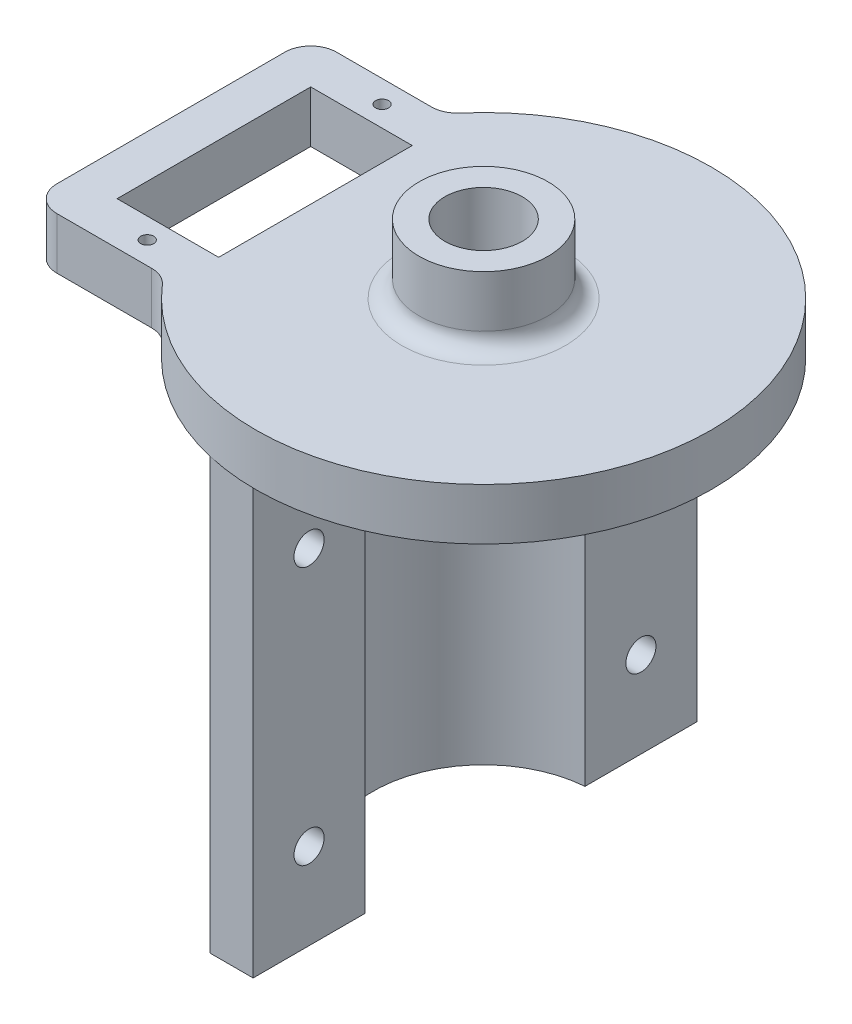
from build123d import *

# Parameters (mm, degrees)
BOSS_EXTRUDE4_DEPTH = 50
SKETCH7_R           = 1.75
CUT_EXTRUDE1_DEPTH  = 17.825
SKETCH8_R           = 0.75
SKETCH8_W           = 11.8
SKETCH8_H           = 22.5
BOSS_EXTRUDE5_DEPTH = 6
SKETCH9_R           = 7.5
BOSS_EXTRUDE6_DEPTH = 8
FILLET1_R           = 2
SKETCH10_R          = 4.5
CUT_EXTRUDE2_DEPTH  = 65


with BuildPart() as part:
    # Sketch6 → Boss-Extrude4 (new body)
    with BuildSketch(Plane.XZ):
        with BuildLine():
            Line((-1, 25.784833184), (-1, 12.785954208))
            ThreePointArc((-1, 12.785954208), (-12.825, 0), (-1, -12.785954208))
            Line((-1, -12.785954208), (-1, -25.784833184))
            Line((-1, -25.784833184), (-6, -25.784833184))
            Line((-6, -25.784833184), (-6, -16.784833184))
            ThreePointArc((-6, -16.784833184), (-17.825, 0), (-6, 16.784833184))
            Line((-6, 16.784833184), (-6, 25.784833184))
            Line((-6, 25.784833184), (-1, 25.784833184))
        make_face()
    extrude(amount=BOSS_EXTRUDE4_DEPTH)

    # Sketch7 → Cut-Extrude1 (cut, through all)
    with BuildSketch(Plane(origin=(-1, 0, 0), x_dir=(0, 0, -1), z_dir=(1, 0, 0))):
        with Locations((-19.285393696, -10)):
            Circle(SKETCH7_R)
        with Locations((-19.285393696, -40)):
            Circle(SKETCH7_R)
        with Locations((19.285393696, -40)):
            Circle(SKETCH7_R)
        with Locations((19.285393696, -10)):
            Circle(SKETCH7_R)
    extrude(amount=-CUT_EXTRUDE1_DEPTH, mode=Mode.SUBTRACT)

    # Sketch8 → Boss-Extrude5 (add)
    with BuildSketch(Plane(origin=(0, 0, 0), x_dir=(1, 0, 0), z_dir=(0, 1, 0))):
        with BuildLine():
            Line((-33.34361413, -16.25), (-22.318992281, -16.25))
            ThreePointArc((-22.318992281, -16.25), (-21.069616181, -16.522536094), (-20.047240136, -17.290627093))
            ThreePointArc((-20.047240136, -17.290627093), (26.473715688, 0), (-20.047240136, 17.290627093))
            ThreePointArc((-20.047240136, 17.290627093), (-21.069616181, 16.522536094), (-22.318992281, 16.25))
            Line((-22.318992281, 16.25), (-33.34361413, 16.25))
            ThreePointArc((-33.34361413, 16.25), (-35.464934474, 15.371320344), (-36.34361413, 13.25))
            Line((-36.34361413, 13.25), (-36.34361413, -13.25))
            ThreePointArc((-36.34361413, -13.25), (-35.464934474, -15.371320344), (-33.34361413, -16.25))
        make_face()
        with Locations((-25.44361413, 13.65)):
            Circle(SKETCH8_R, mode=Mode.SUBTRACT)
        with Locations((-25.44361413, -13.65)):
            Circle(SKETCH8_R, mode=Mode.SUBTRACT)
        with Locations((-25.44361413, 0)):
            Rectangle(SKETCH8_W, SKETCH8_H, mode=Mode.SUBTRACT)
    extrude(amount=BOSS_EXTRUDE5_DEPTH)

    # Sketch9 → Boss-Extrude6 (add)
    with BuildSketch(Plane(origin=(0, 6, 0), x_dir=(1, 0, 0), z_dir=(0, 1, 0))):
        Circle(SKETCH9_R)
    extrude(amount=BOSS_EXTRUDE6_DEPTH)

    # Fillet1
    fillet1_edges = [part.edges().sort_by_distance(p)[0] for p in [
        (-7.5, 6, 0),
    ]]
    fillet(fillet1_edges, radius=FILLET1_R)

    # Sketch10 → Cut-Extrude2 (cut, through all)
    with BuildSketch(Plane(origin=(0, 14, 0), x_dir=(1, 0, 0), z_dir=(0, 1, 0))):
        Circle(SKETCH10_R)
    extrude(amount=-CUT_EXTRUDE2_DEPTH, mode=Mode.SUBTRACT)


solid = part.part
